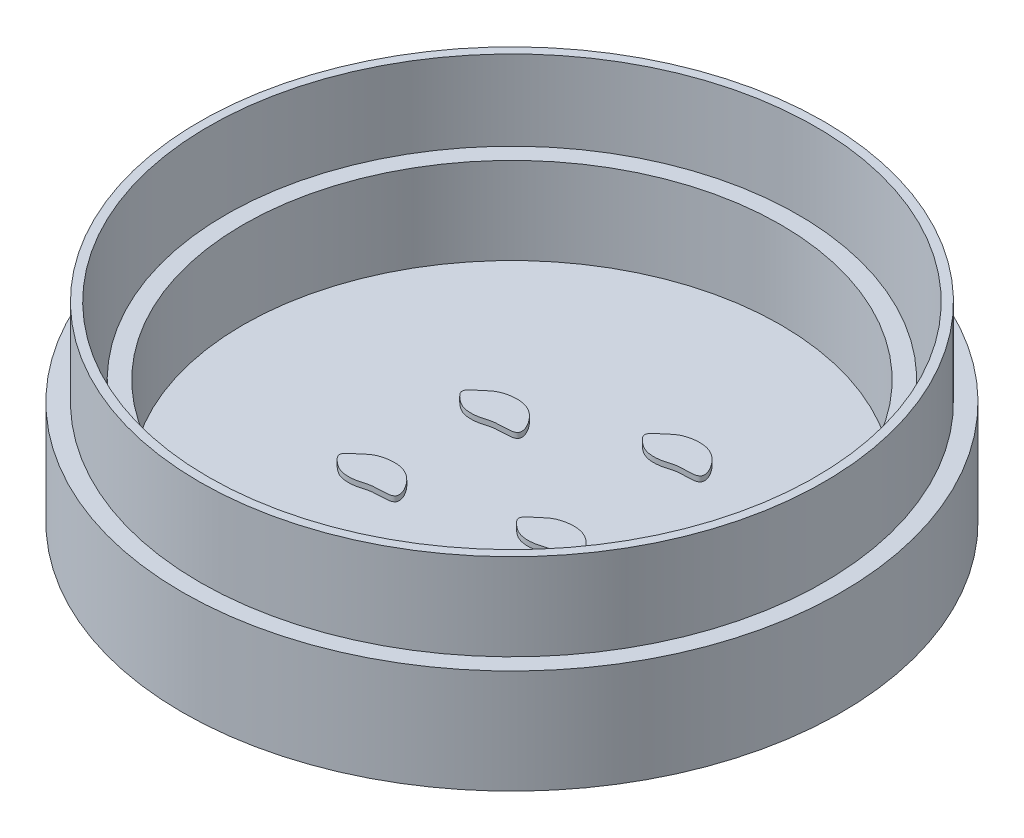
from build123d import *

# Parameters (mm, degrees)
SKETCH1_R           = 19
BOSS_EXTRUDE1_DEPTH = 1
SKETCH2_R           = 19
SKETCH2_R_2         = 17.5
BOSS_EXTRUDE2_DEPTH = 5
SKETCH3_R           = 18
SKETCH3_R_2         = 17.5
BOSS_EXTRUDE3_DEPTH = 5
SKETCH4_R           = 16.5
MEMBRANE_DEPTH      = 0.1
SKETCH5_R           = 16.5
SKETCH5_R_2         = 15.5
BOSS_EXTRUDE5_DEPTH = 5
SLICES_DEPTH        = 0.3
SLICES_2_DEPTH      = 0.3
SLICES_3_DEPTH      = 0.3
SLICES_4_DEPTH      = 0.3
SKETCH7_R           = 17.25
BOSS_EXTRUDE7_DEPTH = 1


with BuildPart() as part:
    # Sketch1 → Boss-Extrude1 (new body)
    with BuildSketch(Plane(origin=(0, 0, 0), x_dir=(1, 0, 0), z_dir=(0, 1, 0))):
        Circle(SKETCH1_R)
    extrude(amount=BOSS_EXTRUDE1_DEPTH)

    # Sketch2 → Boss-Extrude2 (add)
    with BuildSketch(Plane(origin=(0, 1, 0), x_dir=(1, 0, 0), z_dir=(0, 1, 0))):
        Circle(SKETCH2_R)
        Circle(SKETCH2_R_2, mode=Mode.SUBTRACT)
    extrude(amount=BOSS_EXTRUDE2_DEPTH)

    # Sketch3 → Boss-Extrude3 (add)
    with BuildSketch(Plane(origin=(0, 6, 0), x_dir=(1, 0, 0), z_dir=(0, 1, 0))):
        Circle(SKETCH3_R)
        Circle(SKETCH3_R_2, mode=Mode.SUBTRACT)
    extrude(amount=BOSS_EXTRUDE3_DEPTH)


with BuildPart() as body_2:
    # Sketch4 → membrane (new body)
    with BuildSketch(Plane(origin=(0, 2, 0), x_dir=(1, 0, 0), z_dir=(0, 1, 0))):
        Circle(SKETCH4_R)
    extrude(amount=MEMBRANE_DEPTH)


with BuildPart() as body_3:
    # Sketch5 → Boss-Extrude5 (new body)
    with BuildSketch(Plane(origin=(0, 2.1, 0), x_dir=(1, 0, 0), z_dir=(0, 1, 0))):
        Circle(SKETCH5_R)
        Circle(SKETCH5_R_2, mode=Mode.SUBTRACT)
    extrude(amount=BOSS_EXTRUDE5_DEPTH)


with BuildPart() as body_4:
    # Sketch6 → slices (new body)
    with BuildSketch(Plane(origin=(0, 2.1, 0), x_dir=(1, 0, 0), z_dir=(0, 1, 0))):
        with BuildLine():
            add(Edge.make_bspline(
                [(-5.429042639, -3.420339657), (-5.297041768, -3.310830686), (-4.961993019, -2.965303225), (-3.945831341, -2.706421687), (-2.783569857, -3.001085011), (-1.764073176, -4.761079251), (-3.371477913, -4.51450635), (-4.218115468, -4.870930058), (-5.074604653, -4.861818086), (-5.619785113, -4.468520181), (-6.162976614, -3.931834745), (-5.654129434, -3.60707345), (-5.429042639, -3.420339657)],
                knots=[0, 0, 0, 0, 0.051934961, 0.170653906, 0.317123498, 0.463290568, 0.601985486, 0.67644339, 0.792471652, 0.855761907, 0.911440933, 1, 1, 1, 1], degree=3))
        make_face()
    extrude(amount=SLICES_DEPTH)


with BuildPart() as body_5:
    # Sketch6 → slices 2 (new body)
    with BuildSketch(Plane(origin=(0, 2.1, 0), x_dir=(1, 0, 0), z_dir=(0, 1, 0))):
        with BuildLine():
            add(Edge.make_bspline(
                [(-5.059501001, 3.281861232), (-4.92750013, 3.391370203), (-4.592451381, 3.736897664), (-3.576289703, 3.995779201), (-2.414028219, 3.701115877), (-1.394531538, 1.941121638), (-3.001936275, 2.187694539), (-3.84857383, 1.83127083), (-4.705063014, 1.840382802), (-5.250243475, 2.233680708), (-5.793434976, 2.770366144), (-5.284587796, 3.095127439), (-5.059501001, 3.281861232)],
                knots=[0, 0, 0, 0, 0.051934961, 0.170653906, 0.317123498, 0.463290568, 0.601985486, 0.67644339, 0.792471652, 0.855761907, 0.911440933, 1, 1, 1, 1], degree=3))
        make_face()
    extrude(amount=SLICES_2_DEPTH)


with BuildPart() as body_6:
    # Sketch6 → slices 3 (new body)
    with BuildSketch(Plane(origin=(0, 2.1, 0), x_dir=(1, 0, 0), z_dir=(0, 1, 0))):
        with BuildLine():
            add(Edge.make_bspline(
                [(2.375498422, 6.374521352), (2.507499294, 6.484030323), (2.842548043, 6.829557784), (3.85870972, 7.088439322), (5.020971205, 6.793775998), (6.040467885, 5.033781758), (4.433063148, 5.280354659), (3.586425594, 4.923930951), (2.729936409, 4.933042923), (2.184755949, 5.326340828), (1.641564448, 5.863026264), (2.150411627, 6.187787559), (2.375498422, 6.374521352)],
                knots=[0, 0, 0, 0, 0.051934961, 0.170653906, 0.317123498, 0.463290568, 0.601985486, 0.67644339, 0.792471652, 0.855761907, 0.911440933, 1, 1, 1, 1], degree=3))
        make_face()
    extrude(amount=SLICES_3_DEPTH)


with BuildPart() as body_7:
    # Sketch6 → slices 4 (new body)
    with BuildSketch(Plane(origin=(0, 2.1, 0), x_dir=(1, 0, 0), z_dir=(0, 1, 0))):
        with BuildLine():
            add(Edge.make_bspline(
                [(2.919072984, -1.424813087), (3.051073856, -1.315304116), (3.386122605, -0.969776655), (4.402284282, -0.710895118), (5.564545767, -1.005558442), (6.584042447, -2.765552681), (4.97663771, -2.51897978), (4.130000156, -2.875403489), (3.273510971, -2.866291517), (2.728330511, -2.472993611), (2.18513901, -1.936308175), (2.693986189, -1.61154688), (2.919072984, -1.424813087)],
                knots=[0, 0, 0, 0, 0.051934961, 0.170653906, 0.317123498, 0.463290568, 0.601985486, 0.67644339, 0.792471652, 0.855761907, 0.911440933, 1, 1, 1, 1], degree=3))
        make_face()
    extrude(amount=SLICES_4_DEPTH)


with BuildPart() as body_8:
    # Sketch7 → Boss-Extrude7 (new body)
    with BuildSketch(Plane(origin=(0, 1, 0), x_dir=(1, 0, 0), z_dir=(0, 1, 0))):
        Circle(SKETCH7_R)
    extrude(amount=BOSS_EXTRUDE7_DEPTH)


solid = Compound([part.part, body_2.part, body_3.part, body_4.part, body_5.part, body_6.part, body_7.part, body_8.part])
